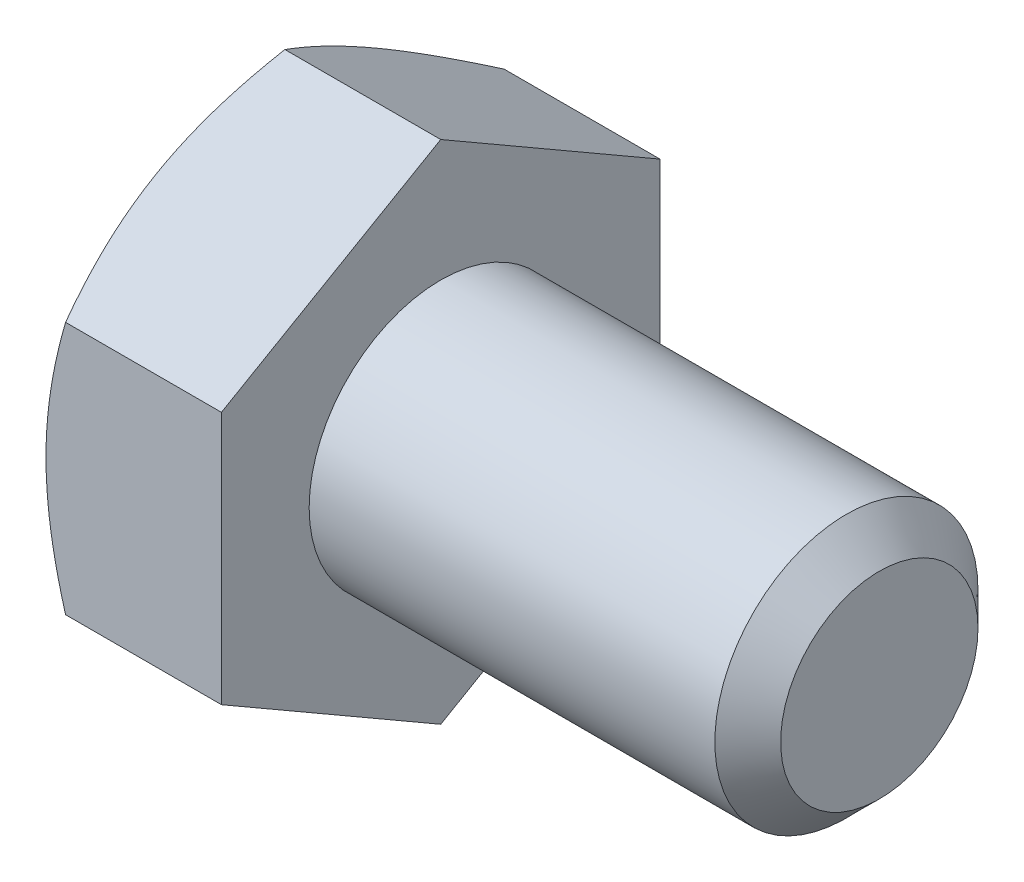
from build123d import *

# Parameters (mm, degrees)
SKETCH2_R           = 3
BOSS_EXTRUDE1_DEPTH = 10
CHAMFER1_SIZE       = 0.75
BOSS_EXTRUDE2_DEPTH = 4
SKETCH6_OUTSIDE_W   = 68.106
SKETCH6_OUTSIDE_H   = 69.654
SKETCH6_OUTSIDE_R   = 5
CUT_EXTRUDE1_DEPTH  = 15
CUT_EXTRUDE1_TAPER  = 60


with BuildPart() as part:
    # Sketch2 → Boss-Extrude1 (new body)
    with BuildSketch(Plane(origin=(7, 0, 0), x_dir=(0, 0, -1), z_dir=(1, 0, 0))):
        Circle(SKETCH2_R)
    extrude(amount=-BOSS_EXTRUDE1_DEPTH)

    # Chamfer1
    chamfer1_edges = [part.edges().sort_by_distance(p)[0] for p in [
        (7, 0, 3),
    ]]
    chamfer(chamfer1_edges, length=CHAMFER1_SIZE)

    # Sketch3 → Boss-Extrude2 (add)
    with BuildSketch(Plane.ZY.offset(3)):
        Polygon((-5, -2.886751346), (0, -5.773502692), (5, -2.886751346), (5, 2.886751346), (0, 5.773502692), (-5, 2.886751346), align=None)
    extrude(amount=BOSS_EXTRUDE2_DEPTH)

    # Sketch6 outside → Cut-Extrude1 (cut, through all)
    with BuildSketch(Plane.ZY.offset(7)):
        Rectangle(SKETCH6_OUTSIDE_W, SKETCH6_OUTSIDE_H)
        Circle(SKETCH6_OUTSIDE_R, mode=Mode.SUBTRACT)
    extrude(amount=-CUT_EXTRUDE1_DEPTH, taper=CUT_EXTRUDE1_TAPER, mode=Mode.SUBTRACT)


solid = part.part
